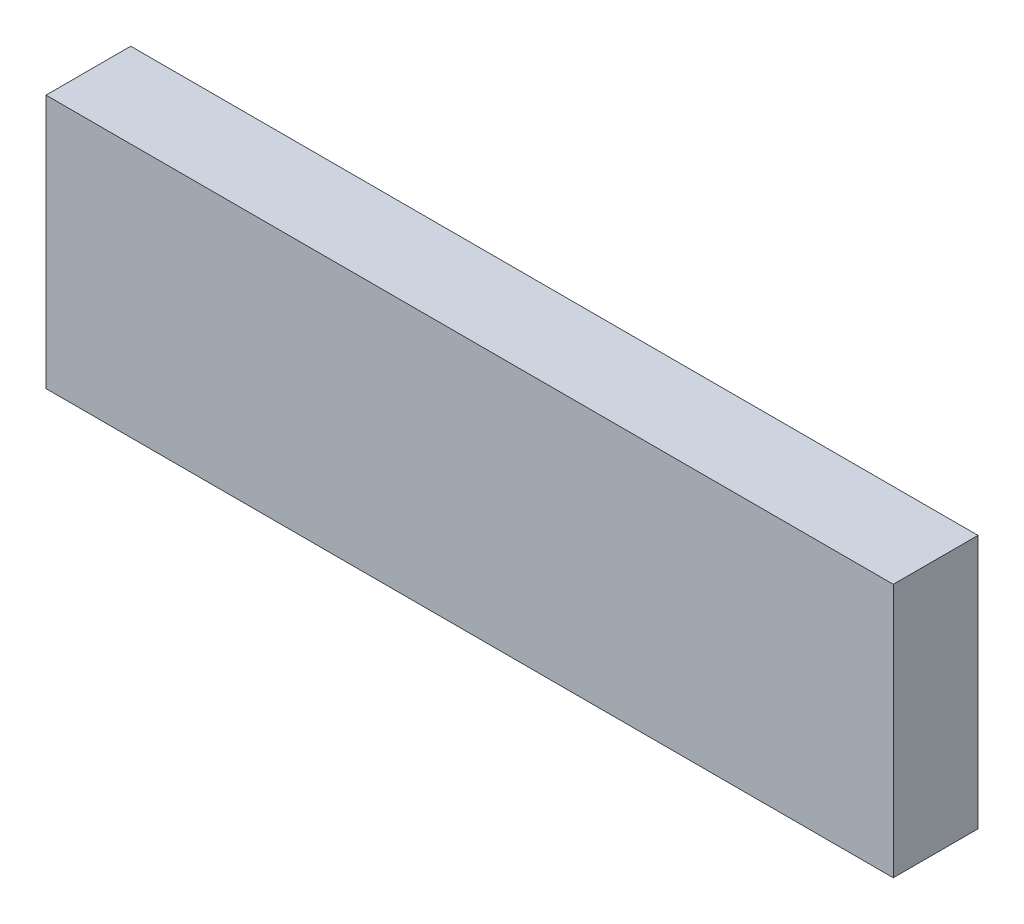
from build123d import *

# Parameters (mm, degrees)
SKETCH1_W           = 100
SKETCH1_H           = 30
BOSS_EXTRUDE1_DEPTH = 10


with BuildPart() as part:
    # Sketch1 → Boss-Extrude1 (new body)
    with BuildSketch(Plane.XY):
        with Locations((-38.348561098, 27.543981747)):
            Rectangle(SKETCH1_W, SKETCH1_H)
    extrude(amount=BOSS_EXTRUDE1_DEPTH)


solid = part.part
